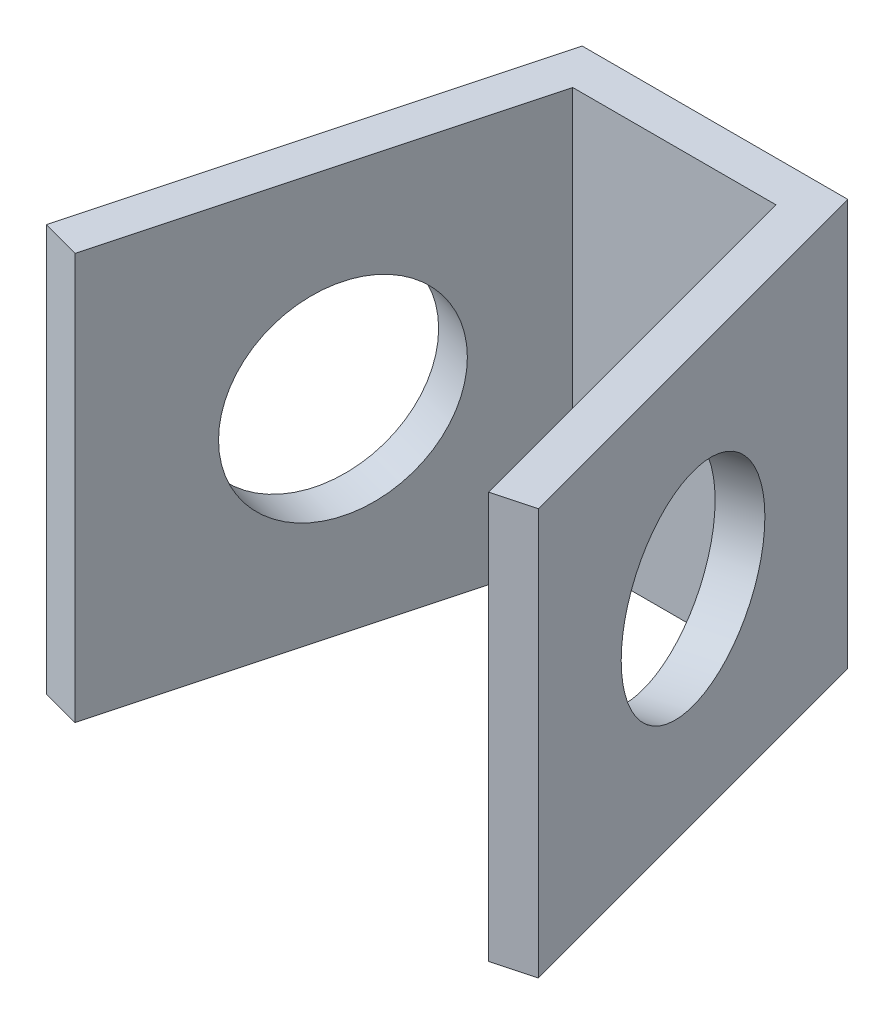
from build123d import *

# Parameters (mm, degrees)
AUFSATZ_LINEAR_AUSTRAGEN1_DEPTH = 10
SKIZZE2_R                       = 5
SCHNITT_LINEAR_AUSTRAGEN1_DEPTH = 2


with BuildPart() as part:
    # Skizze1 → Aufsatz-Linear austragen1 (new body, symmetric)
    with BuildSketch(Plane(origin=(0, 0, 0), x_dir=(1, 0, 0), z_dir=(0, 1, 0))):
        Polygon((-5, 0), (-10.176380902, -19.318516526), (-12.108232555, -18.800878436), (-6.534653976, 2), (6.534653976, 2), (12.108232555, -18.800878436), (10.176380902, -19.318516526), (5, 0), align=None)
    extrude(amount=AUFSATZ_LINEAR_AUSTRAGEN1_DEPTH, both=True)

    # Skizze2 → Schnitt-Linear austragen1 (cut)
    with BuildSketch(Plane(origin=(6.596915162, 0, -1.76763809), x_dir=(-0.258819045, 0, -0.965925826), z_dir=(0.965925826, 0, -0.258819045))):
        with Locations((-10.526768238, 0)):
            Circle(SKIZZE2_R)
    schnitt_linear_austragen1 = extrude(amount=-SCHNITT_LINEAR_AUSTRAGEN1_DEPTH, mode=Mode.SUBTRACT)

    # Spiegeln1: Schnitt-Linear austragen1 across plane
    add(schnitt_linear_austragen1.mirror(Plane(origin=(0, 0, 0), x_dir=(0, 0, 1), z_dir=(1, 0, 0))), mode=Mode.SUBTRACT)


solid = part.part
